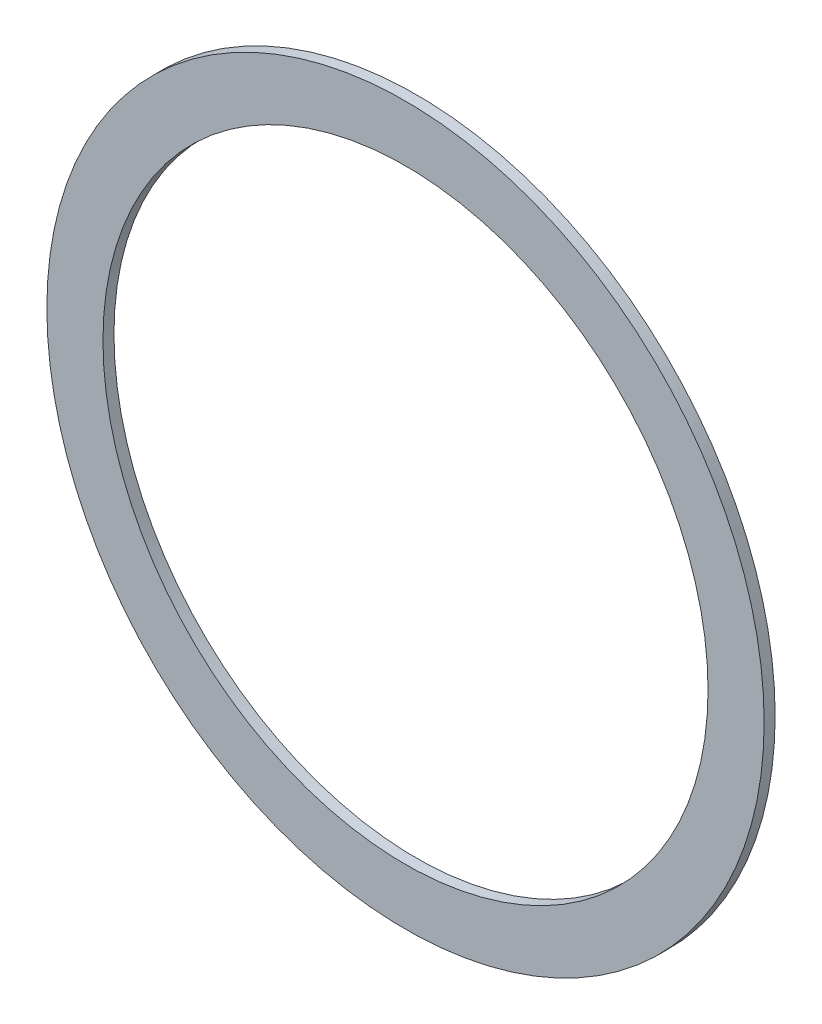
from build123d import *

# Parameters (mm, degrees)
SKETCH1_R           = 3.586563548
SKETCH1_R_2         = 2.75
BOSS_EXTRUDE1_DEPTH = 0.1
SKETCH2_R           = 4.144167201
SKETCH2_R_2         = 3.26
CUT_EXTRUDE1_DEPTH  = 10


with BuildPart() as part:
    # Sketch1 → Boss-Extrude1 (new body)
    with BuildSketch(Plane.XY):
        Circle(SKETCH1_R)
        Circle(SKETCH1_R_2, mode=Mode.SUBTRACT)
    extrude(amount=BOSS_EXTRUDE1_DEPTH)

    # Sketch2 → Cut-Extrude1 (cut)
    with BuildSketch(Plane.XY.offset(0.1)):
        Circle(SKETCH2_R)
        Circle(SKETCH2_R_2, mode=Mode.SUBTRACT)
    extrude(amount=-CUT_EXTRUDE1_DEPTH, mode=Mode.SUBTRACT)


solid = part.part
